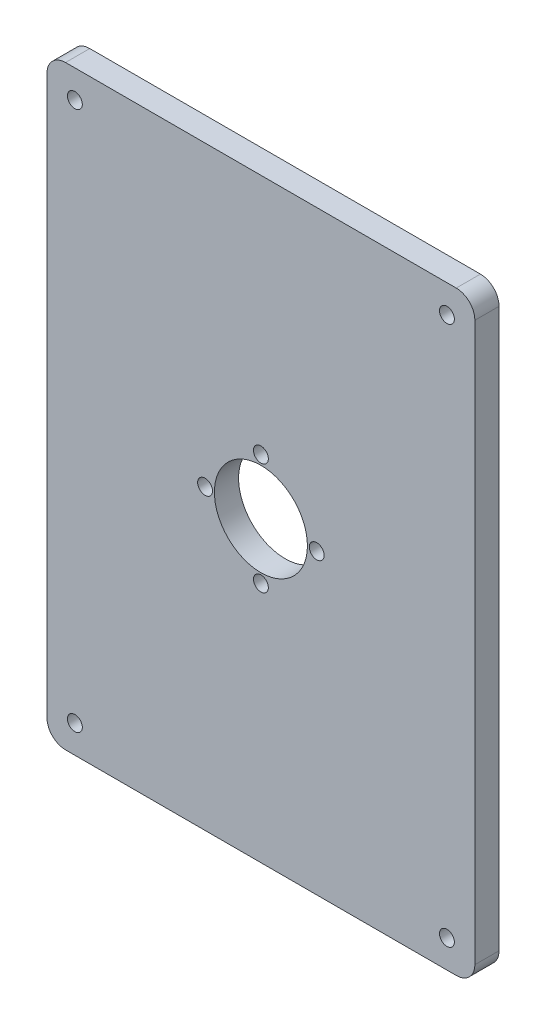
from build123d import *

# Parameters (mm, degrees)
CROQUIS2_R              = 4
SALIENTE_EXTRUIR1_DEPTH = 13
CROQUIS3_R              = 25
CORTAR_EXTRUIR1_DEPTH   = 198.468984906
CROQUIS3_3_R            = 4
CORTAR_EXTRUIR2_DEPTH   = 198.468984906


with BuildPart() as part:
    # Croquis2 → Saliente-Extruir1 (new body)
    with BuildSketch(Plane.XY):
        with BuildLine():
            Line((-105, 160), (105, 160))
            ThreePointArc((105, 160), (112.071067812, 157.071067812), (115, 150))
            Line((115, 150), (115, -150))
            ThreePointArc((115, -150), (112.071067812, -157.071067812), (105, -160))
            Line((105, -160), (-105, -160))
            ThreePointArc((-105, -160), (-112.071067812, -157.071067812), (-115, -150))
            Line((-115, -150), (-115, 150))
            ThreePointArc((-115, 150), (-112.071067812, 157.071067812), (-105, 160))
        make_face()
        with Locations((-100, -145)):
            Circle(CROQUIS2_R, mode=Mode.SUBTRACT)
        with Locations((-100, 145)):
            Circle(CROQUIS2_R, mode=Mode.SUBTRACT)
        with Locations((100, -145)):
            Circle(CROQUIS2_R, mode=Mode.SUBTRACT)
        with Locations((100, 145)):
            Circle(CROQUIS2_R, mode=Mode.SUBTRACT)
    extrude(amount=SALIENTE_EXTRUIR1_DEPTH)

    # Croquis3 → Cortar-Extruir1 (cut, through all)
    with BuildSketch(Plane.XY.offset(13)):
        Circle(CROQUIS3_R)
    extrude(amount=-CORTAR_EXTRUIR1_DEPTH, mode=Mode.SUBTRACT)

    # Croquis3_3 → Cortar-Extruir2 (cut, through all)
    with BuildSketch(Plane.XY.offset(13)):
        with Locations((30, 0)):
            Circle(CROQUIS3_3_R)
        with Locations((0, 30)):
            Circle(CROQUIS3_3_R)
        with Locations((-30, 0)):
            Circle(CROQUIS3_3_R)
        with Locations((0, -30)):
            Circle(CROQUIS3_3_R)
    extrude(amount=-CORTAR_EXTRUIR2_DEPTH, mode=Mode.SUBTRACT)


solid = part.part
